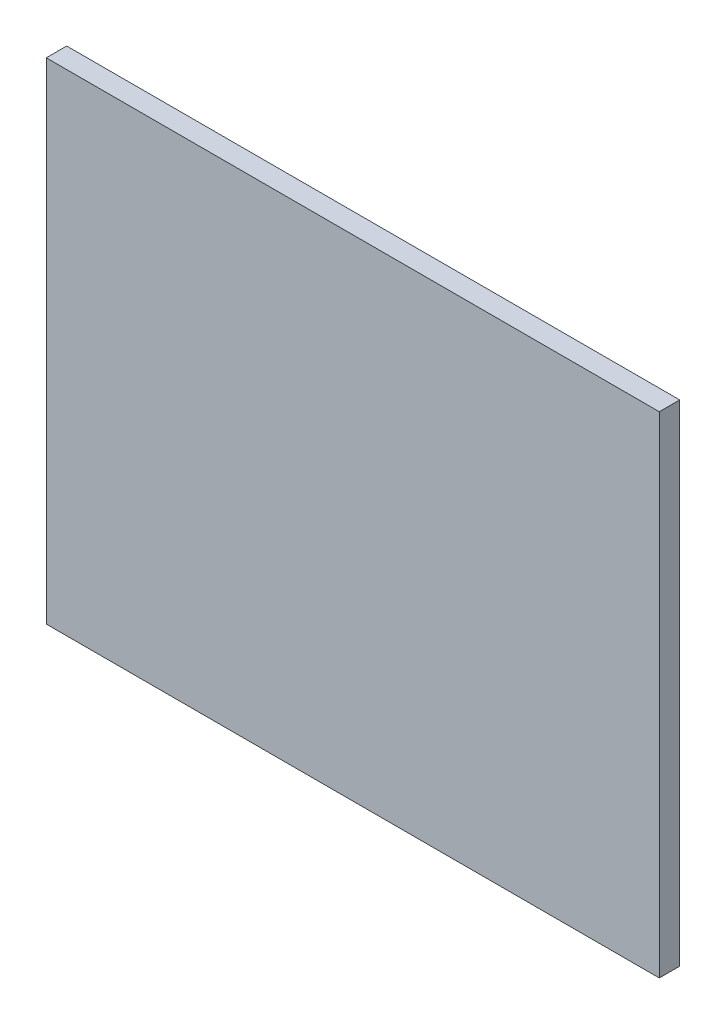
from build123d import *

# Parameters (mm, degrees)
SKETCH1_W           = 381
SKETCH1_H           = 304.8
BOSS_EXTRUDE1_DEPTH = 12.7


with BuildPart() as part:
    # Sketch1 → Boss-Extrude1 (new body)
    with BuildSketch(Plane.XY):
        with Locations((-190.5, 152.4)):
            Rectangle(SKETCH1_W, SKETCH1_H)
    extrude(amount=BOSS_EXTRUDE1_DEPTH)


solid = part.part
